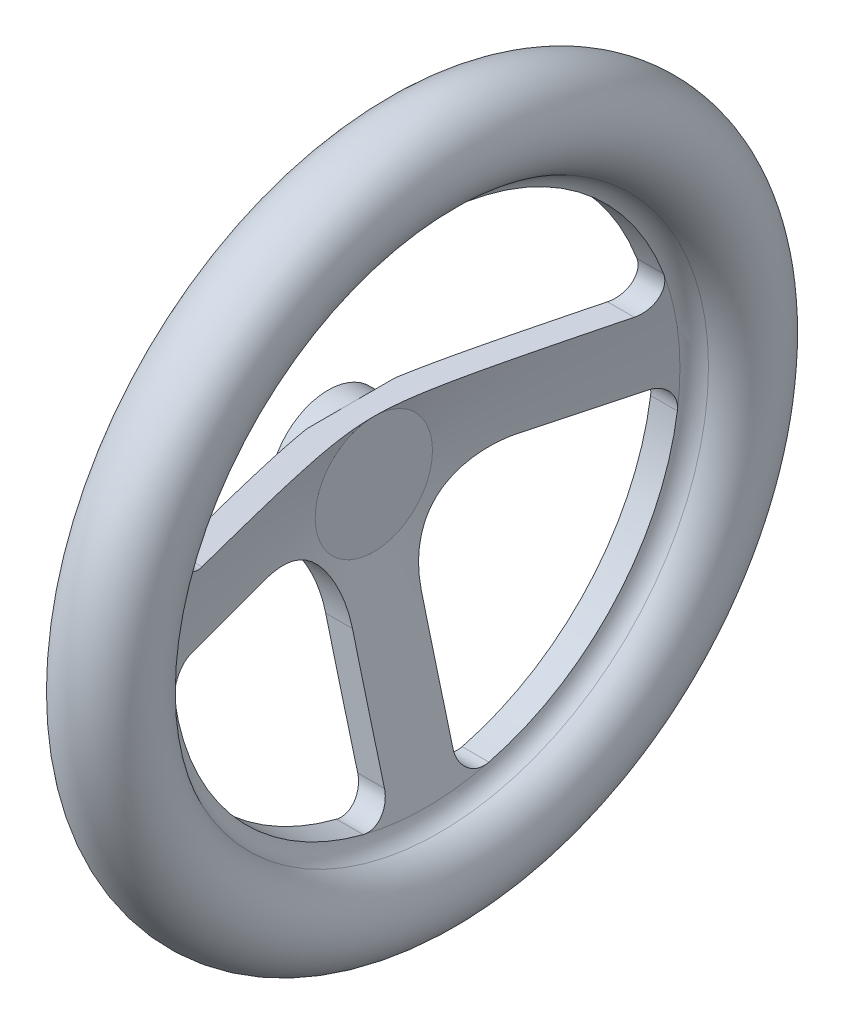
from build123d import *

# Parameters (mm, degrees)
SKETCH3_R           = 32.568935498
BOSS_EXTRUDE1_DEPTH = 25.4
CUT_EXTRUDE1_DEPTH  = 65.782558538


with BuildPart() as part:
    # Sketch1 → Revolve1 (revolve)
    with BuildSketch(Plane.XY):
        with BuildLine():
            Line((0, 0), (12.7, 0))
            Line((12.7, 0), (12.7, -32.568935498))
            Line((12.7, -32.568935498), (41.754780606, -141.002852921))
            ThreePointArc((41.754780606, -141.002852921), (44.473168727, -146.088967801), (49.16054569, -149.448535595))
            ThreePointArc((49.16054569, -149.448535595), (43.522420897, -197.816221792), (22.891151455, -153.707580457))
            ThreePointArc((22.891151455, -153.707580457), (26.714350783, -147.832951554), (26.83896106, -140.824914016))
            Line((26.83896106, -140.824914016), (0, -40.660547717))
            Line((0, -40.660547717), (0, 0))
        make_face()
    revolve(axis=Axis((0, 0, 0), (1, 0, 0)))

    # Sketch3 → Boss-Extrude1 (add)
    with BuildSketch(Plane(origin=(12.7, 0, 0), x_dir=(0, 0, -1), z_dir=(1, 0, 0))):
        Circle(SKETCH3_R)
    extrude(amount=-BOSS_EXTRUDE1_DEPTH)

    # Sketch4 → Cut-Extrude1 (cut, through all)
    with BuildSketch(Plane(origin=(0, 0, 0), x_dir=(0, 0, -1), z_dir=(1, 0, 0))):
        with BuildLine():
            ThreePointArc((-131.934665259, 49.749860651), (0, 141.002852921), (131.934665259, 49.749860651))
            ThreePointArc((131.934665259, 49.749860651), (130.496469432, 38.044592948), (120.051428757, 32.568935498))
            Line((120.051428757, 32.568935498), (0, 32.568935498))
            Line((0, 32.568935498), (-120.051428757, 32.568935498))
            ThreePointArc((-120.051428757, 32.568935498), (-130.496469432, 38.044592948), (-131.934665259, 49.749860651))
        make_face()
        with BuildLine():
            ThreePointArc((-139.5721209, -20.035658195), (-104.915781638, -94.204475982), (-34.892759423, -136.617348355))
            ThreePointArc((-34.892759423, -136.617348355), (-23.959719025, -134.342377826), (-19.05, -124.312346803))
            Line((-19.05, -124.312346803), (-19.05, -56.331064502))
            ThreePointArc((-19.05, -56.331064502), (-33.928975516, -20.410040018), (-69.85, -5.531064502))
            Line((-69.85, -5.531064502), (-127.000985645, -5.531064502))
            ThreePointArc((-127.000985645, -5.531064502), (-136.598077389, -9.913262506), (-139.5721209, -20.035658195))
        make_face()
        with BuildLine():
            ThreePointArc((34.892759423, -136.617348355), (104.915781638, -94.204475982), (139.5721209, -20.035658195))
            ThreePointArc((139.5721209, -20.035658195), (136.598077389, -9.913262506), (127.000985645, -5.531064502))
            Line((127.000985645, -5.531064502), (69.85, -5.531064502))
            ThreePointArc((69.85, -5.531064502), (33.928975516, -20.410040018), (19.05, -56.331064502))
            Line((19.05, -56.331064502), (19.05, -124.312346803))
            ThreePointArc((19.05, -124.312346803), (23.959719025, -134.342377826), (34.892759423, -136.617348355))
        make_face()
    extrude(amount=CUT_EXTRUDE1_DEPTH, mode=Mode.SUBTRACT)


solid = part.part
